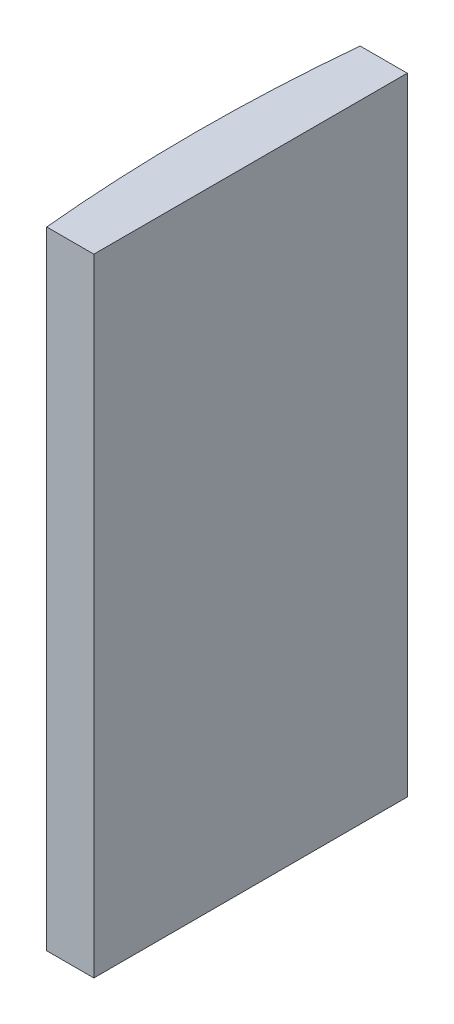
from build123d import *

# Parameters (mm, degrees)
EXTRUDE_1_DEPTH = 40


with BuildPart() as part:
    # 草图1 → 凸台-拉伸1 (new body)
    with BuildSketch(Plane(origin=(0, 0, 0), x_dir=(1, 0, 0), z_dir=(0, 1, 0))):
        with BuildLine():
            Line((-98.560100649, 10), (-95.554795665, 10))
            Line((-95.554795665, 10), (-95.554795665, -10))
            Line((-95.554795665, -10), (-98.560100649, -10))
            ThreePointArc((-98.560100649, -10), (-99.044795665, 0), (-98.560100649, 10))
        make_face()
    extrude(amount=EXTRUDE_1_DEPTH)


solid = part.part
